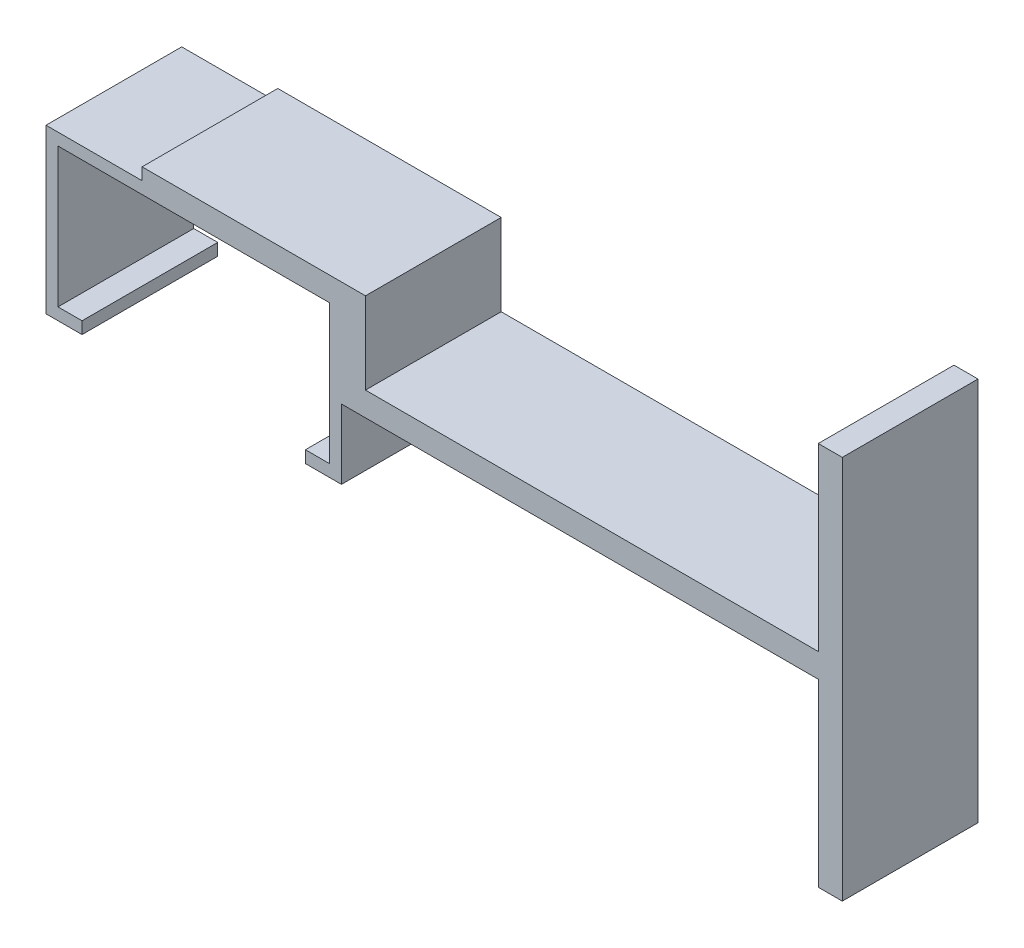
from build123d import *

# Parameters (mm, degrees)
BOSS_EXTRU_1_DEPTH = 11.3
ESQUISSE2_W        = 8.6
ESQUISSE2_H        = 11.3
BOSS_EXTRU_2_DEPTH = 1
ESQUISSE8_W        = 11.3
ESQUISSE8_H        = 1
BOSS_EXTRU_5_DEPTH = 10
ESQUISSE9_W        = 2
ESQUISSE9_H        = 11.3
BOSS_EXTRU_6_DEPTH = 7.8
ESQUISSE10_W       = 11.3
ESQUISSE10_H       = 2
BOSS_EXTRU_7_DEPTH = 39.7
ESQUISSE11_W       = 2
ESQUISSE11_H       = 11.3
BOSS_EXTRU_8_DEPTH = 15
ESQUISSE12_W       = 2
ESQUISSE12_H       = 11.3
BOSS_EXTRU_9_DEPTH = 15


with BuildPart() as part:
    # Esquisse1 → Boss.-Extru.1 (new body)
    with BuildSketch(Plane.XY):
        Polygon((-21.6, 1), (-21.6, 0), (-24.6, 0), (-24.6, 13.6), (0, 13.6), (0, 0), (-3, 0), (-3, 1), (-1, 1), (-1, 12.6), (-23.6, 12.6), (-23.6, 1), align=None)
    extrude(amount=BOSS_EXTRU_1_DEPTH)

    # Esquisse2 → Boss.-Extru.2 (add)
    with BuildSketch(Plane(origin=(0, 13.6, 0), x_dir=(1, 0, 0), z_dir=(0, 1, 0))):
        with Locations((-12.3, -5.65)):
            Rectangle(ESQUISSE2_W, ESQUISSE2_H)
    extrude(amount=BOSS_EXTRU_2_DEPTH)

    # Esquisse8 → Boss.-Extru.5 (add)
    with BuildSketch(Plane(origin=(-8, 0, 0), x_dir=(0, 0, -1), z_dir=(1, 0, 0))):
        with Locations((-5.65, 14.1)):
            Rectangle(ESQUISSE8_W, ESQUISSE8_H)
    extrude(amount=BOSS_EXTRU_5_DEPTH)

    # Esquisse9 → Boss.-Extru.6 (add)
    with BuildSketch(Plane.XZ.offset(-13.6)):
        with Locations((1, 5.65)):
            Rectangle(ESQUISSE9_W, ESQUISSE9_H)
    extrude(amount=BOSS_EXTRU_6_DEPTH)

    # Esquisse10 → Boss.-Extru.7 (add)
    with BuildSketch(Plane(origin=(2, 0, 0), x_dir=(0, 0, -1), z_dir=(1, 0, 0))):
        with Locations((-5.65, 6.8)):
            Rectangle(ESQUISSE10_W, ESQUISSE10_H)
    extrude(amount=BOSS_EXTRU_7_DEPTH)

    # Esquisse11 → Boss.-Extru.8 (add)
    with BuildSketch(Plane.XZ.offset(-5.8)):
        with Locations((40.7, 5.65)):
            Rectangle(ESQUISSE11_W, ESQUISSE11_H)
    extrude(amount=BOSS_EXTRU_8_DEPTH)

    # Esquisse12 → Boss.-Extru.9 (add)
    with BuildSketch(Plane(origin=(0, 7.8, 0), x_dir=(1, 0, 0), z_dir=(0, 1, 0))):
        with Locations((40.7, -5.65)):
            Rectangle(ESQUISSE12_W, ESQUISSE12_H)
    extrude(amount=BOSS_EXTRU_9_DEPTH)


solid = part.part
